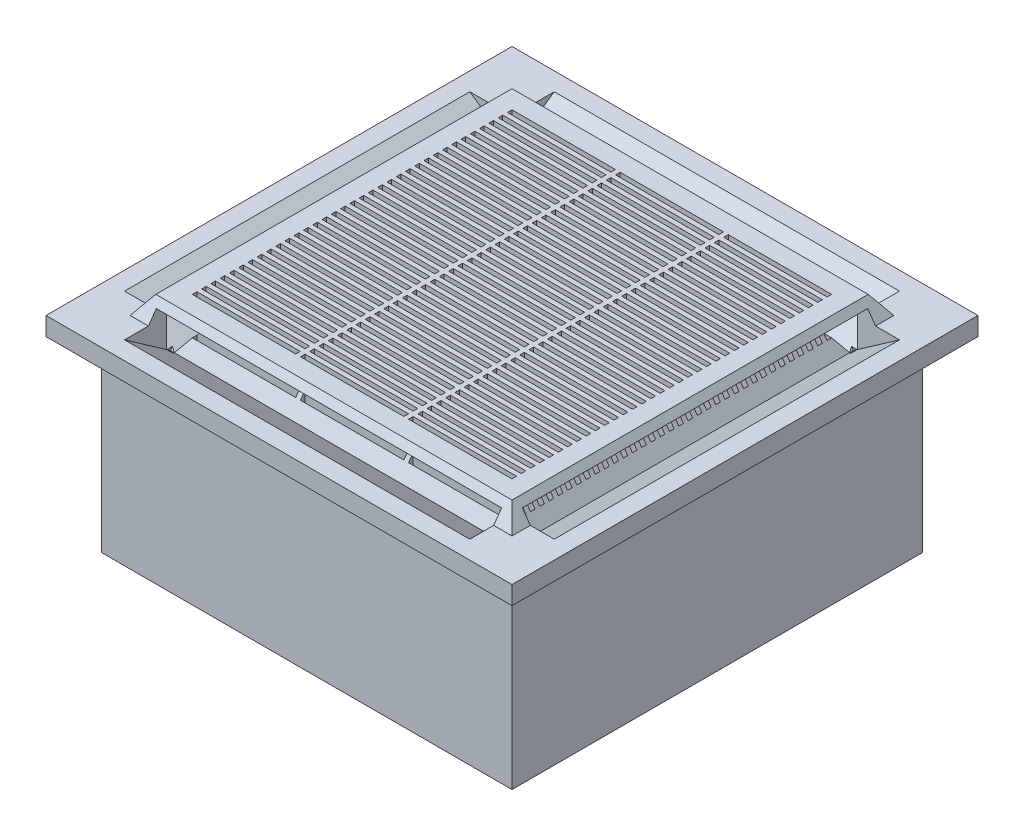
from build123d import *

# Parameters (mm, degrees)
SKETCH1_W           = 569.976
SKETCH1_H           = 569.976
BOSS_EXTRUDE1_DEPTH = 260.096
SKETCH3_W           = 646.938
SKETCH3_H           = 646.938
BOSS_EXTRUDE2_DEPTH = 50.8
SKETCH4_W           = 143.51
SKETCH4_H           = 6.35
CUT_EXTRUDE2_DEPTH  = 101.6
SKETCH5_W           = 799.338
SKETCH5_H           = 799.338
SKETCH5_W_2         = 494.538
SKETCH5_H_2         = 494.538
CUT_EXTRUDE3_DEPTH  = 25.4
CUT_EXTRUDE3_TAPER  = 35
SKETCH6_W           = 479.308542942
SKETCH6_H           = 38.1
CUT_EXTRUDE4_DEPTH  = 50.8
SKETCH7_W           = 479.308542942
SKETCH7_H           = 38.1
CUT_EXTRUDE5_DEPTH  = 50.8
SKETCH8_W           = 479.308542942
SKETCH8_H           = 38.1
CUT_EXTRUDE6_DEPTH  = 50.8
SKETCH9_W           = 479.308542942
SKETCH9_H           = 38.1
CUT_EXTRUDE7_DEPTH  = 50.8
SKETCH10_W          = 544.576
SKETCH10_H          = 544.576
CUT_EXTRUDE8_DEPTH  = 221.996


with BuildPart() as part:
    # Sketch1 → Boss-Extrude1 (new body)
    with BuildSketch(Plane(origin=(0, 0, 0), x_dir=(1, 0, 0), z_dir=(0, 1, 0))):
        Rectangle(SKETCH1_W, SKETCH1_H)
    extrude(amount=BOSS_EXTRUDE1_DEPTH)

    # Sketch3 → Boss-Extrude2 (add)
    with BuildSketch(Plane(origin=(0, 260.096, 0), x_dir=(1, 0, 0), z_dir=(0, 1, 0))):
        with Locations((0.508, -0.508)):
            Rectangle(SKETCH3_W, SKETCH3_H)
    extrude(amount=BOSS_EXTRUDE2_DEPTH)

    # Sketch4 → Cut-Extrude2 (cut)
    with BuildSketch(Plane(origin=(0, 310.896, 0), x_dir=(1, 0, 0), z_dir=(0, 1, 0))):
        with Locations((-149.606, 218.186)):
            Rectangle(SKETCH4_W, SKETCH4_H)
        with Locations((0.508, 218.186)):
            Rectangle(SKETCH4_W, SKETCH4_H)
        with Locations((150.622, 218.186)):
            Rectangle(SKETCH4_W, SKETCH4_H)
        with Locations((0.508, 205.321647059)):
            Rectangle(SKETCH4_W, SKETCH4_H)
        with Locations((150.622, 205.321647059)):
            Rectangle(SKETCH4_W, SKETCH4_H)
        with Locations((0.508, 192.457294118)):
            Rectangle(SKETCH4_W, SKETCH4_H)
        with Locations((150.622, 192.457294118)):
            Rectangle(SKETCH4_W, SKETCH4_H)
        with Locations((0.508, 179.592941176)):
            Rectangle(SKETCH4_W, SKETCH4_H)
        with Locations((150.622, 179.592941176)):
            Rectangle(SKETCH4_W, SKETCH4_H)
        with Locations((0.508, 166.728588235)):
            Rectangle(SKETCH4_W, SKETCH4_H)
        with Locations((150.622, 166.728588235)):
            Rectangle(SKETCH4_W, SKETCH4_H)
        with Locations((0.508, 153.864235294)):
            Rectangle(SKETCH4_W, SKETCH4_H)
        with Locations((150.622, 153.864235294)):
            Rectangle(SKETCH4_W, SKETCH4_H)
        with Locations((0.508, 140.999882353)):
            Rectangle(SKETCH4_W, SKETCH4_H)
        with Locations((150.622, 140.999882353)):
            Rectangle(SKETCH4_W, SKETCH4_H)
        with Locations((0.508, 128.135529412)):
            Rectangle(SKETCH4_W, SKETCH4_H)
        with Locations((150.622, 128.135529412)):
            Rectangle(SKETCH4_W, SKETCH4_H)
        with Locations((0.508, 115.271176471)):
            Rectangle(SKETCH4_W, SKETCH4_H)
        with Locations((150.622, 115.271176471)):
            Rectangle(SKETCH4_W, SKETCH4_H)
        with Locations((0.508, 102.406823529)):
            Rectangle(SKETCH4_W, SKETCH4_H)
        with Locations((150.622, 102.406823529)):
            Rectangle(SKETCH4_W, SKETCH4_H)
        with Locations((0.508, 89.542470588)):
            Rectangle(SKETCH4_W, SKETCH4_H)
        with Locations((150.622, 89.542470588)):
            Rectangle(SKETCH4_W, SKETCH4_H)
        with Locations((0.508, 76.678117647)):
            Rectangle(SKETCH4_W, SKETCH4_H)
        with Locations((150.622, 76.678117647)):
            Rectangle(SKETCH4_W, SKETCH4_H)
        with Locations((0.508, 63.813764706)):
            Rectangle(SKETCH4_W, SKETCH4_H)
        with Locations((150.622, 63.813764706)):
            Rectangle(SKETCH4_W, SKETCH4_H)
        with Locations((0.508, 50.949411765)):
            Rectangle(SKETCH4_W, SKETCH4_H)
        with Locations((150.622, 50.949411765)):
            Rectangle(SKETCH4_W, SKETCH4_H)
        with Locations((0.508, 38.085058824)):
            Rectangle(SKETCH4_W, SKETCH4_H)
        with Locations((150.622, 38.085058824)):
            Rectangle(SKETCH4_W, SKETCH4_H)
        with Locations((0.508, 25.220705882)):
            Rectangle(SKETCH4_W, SKETCH4_H)
        with Locations((150.622, 25.220705882)):
            Rectangle(SKETCH4_W, SKETCH4_H)
        with Locations((0.508, 12.356352941)):
            Rectangle(SKETCH4_W, SKETCH4_H)
        with Locations((150.622, 12.356352941)):
            Rectangle(SKETCH4_W, SKETCH4_H)
        with Locations((0.508, -0.508)):
            Rectangle(SKETCH4_W, SKETCH4_H)
        with Locations((150.622, -0.508)):
            Rectangle(SKETCH4_W, SKETCH4_H)
        with Locations((0.508, -13.372352941)):
            Rectangle(SKETCH4_W, SKETCH4_H)
        with Locations((150.622, -13.372352941)):
            Rectangle(SKETCH4_W, SKETCH4_H)
        with Locations((0.508, -26.236705882)):
            Rectangle(SKETCH4_W, SKETCH4_H)
        with Locations((150.622, -26.236705882)):
            Rectangle(SKETCH4_W, SKETCH4_H)
        with Locations((0.508, -39.101058824)):
            Rectangle(SKETCH4_W, SKETCH4_H)
        with Locations((150.622, -39.101058824)):
            Rectangle(SKETCH4_W, SKETCH4_H)
        with Locations((0.508, -51.965411765)):
            Rectangle(SKETCH4_W, SKETCH4_H)
        with Locations((150.622, -51.965411765)):
            Rectangle(SKETCH4_W, SKETCH4_H)
        with Locations((0.508, -64.829764706)):
            Rectangle(SKETCH4_W, SKETCH4_H)
        with Locations((150.622, -64.829764706)):
            Rectangle(SKETCH4_W, SKETCH4_H)
        with Locations((0.508, -77.694117647)):
            Rectangle(SKETCH4_W, SKETCH4_H)
        with Locations((150.622, -77.694117647)):
            Rectangle(SKETCH4_W, SKETCH4_H)
        with Locations((0.508, -90.558470588)):
            Rectangle(SKETCH4_W, SKETCH4_H)
        with Locations((150.622, -90.558470588)):
            Rectangle(SKETCH4_W, SKETCH4_H)
        with Locations((0.508, -103.422823529)):
            Rectangle(SKETCH4_W, SKETCH4_H)
        with Locations((150.622, -103.422823529)):
            Rectangle(SKETCH4_W, SKETCH4_H)
        with Locations((0.508, -116.287176471)):
            Rectangle(SKETCH4_W, SKETCH4_H)
        with Locations((150.622, -116.287176471)):
            Rectangle(SKETCH4_W, SKETCH4_H)
        with Locations((0.508, -129.151529412)):
            Rectangle(SKETCH4_W, SKETCH4_H)
        with Locations((150.622, -129.151529412)):
            Rectangle(SKETCH4_W, SKETCH4_H)
        with Locations((0.508, -142.015882353)):
            Rectangle(SKETCH4_W, SKETCH4_H)
        with Locations((150.622, -142.015882353)):
            Rectangle(SKETCH4_W, SKETCH4_H)
        with Locations((0.508, -154.880235294)):
            Rectangle(SKETCH4_W, SKETCH4_H)
        with Locations((150.622, -154.880235294)):
            Rectangle(SKETCH4_W, SKETCH4_H)
        with Locations((0.508, -167.744588235)):
            Rectangle(SKETCH4_W, SKETCH4_H)
        with Locations((150.622, -167.744588235)):
            Rectangle(SKETCH4_W, SKETCH4_H)
        with Locations((0.508, -180.608941176)):
            Rectangle(SKETCH4_W, SKETCH4_H)
        with Locations((150.622, -180.608941176)):
            Rectangle(SKETCH4_W, SKETCH4_H)
        with Locations((0.508, -193.473294118)):
            Rectangle(SKETCH4_W, SKETCH4_H)
        with Locations((150.622, -193.473294118)):
            Rectangle(SKETCH4_W, SKETCH4_H)
        with Locations((0.508, -206.337647059)):
            Rectangle(SKETCH4_W, SKETCH4_H)
        with Locations((150.622, -206.337647059)):
            Rectangle(SKETCH4_W, SKETCH4_H)
        with Locations((0.508, -219.202)):
            Rectangle(SKETCH4_W, SKETCH4_H)
        with Locations((150.622, -219.202)):
            Rectangle(SKETCH4_W, SKETCH4_H)
        with Locations((-149.606, 205.321647059)):
            Rectangle(SKETCH4_W, SKETCH4_H)
        with Locations((-149.606, 192.457294118)):
            Rectangle(SKETCH4_W, SKETCH4_H)
        with Locations((-149.606, 179.592941176)):
            Rectangle(SKETCH4_W, SKETCH4_H)
        with Locations((-149.606, 166.728588235)):
            Rectangle(SKETCH4_W, SKETCH4_H)
        with Locations((-149.606, 153.864235294)):
            Rectangle(SKETCH4_W, SKETCH4_H)
        with Locations((-149.606, 140.999882353)):
            Rectangle(SKETCH4_W, SKETCH4_H)
        with Locations((-149.606, 128.135529412)):
            Rectangle(SKETCH4_W, SKETCH4_H)
        with Locations((-149.606, 115.271176471)):
            Rectangle(SKETCH4_W, SKETCH4_H)
        with Locations((-149.606, 102.406823529)):
            Rectangle(SKETCH4_W, SKETCH4_H)
        with Locations((-149.606, 89.542470588)):
            Rectangle(SKETCH4_W, SKETCH4_H)
        with Locations((-149.606, 76.678117647)):
            Rectangle(SKETCH4_W, SKETCH4_H)
        with Locations((-149.606, 63.813764706)):
            Rectangle(SKETCH4_W, SKETCH4_H)
        with Locations((-149.606, 50.949411765)):
            Rectangle(SKETCH4_W, SKETCH4_H)
        with Locations((-149.606, 38.085058824)):
            Rectangle(SKETCH4_W, SKETCH4_H)
        with Locations((-149.606, 25.220705882)):
            Rectangle(SKETCH4_W, SKETCH4_H)
        with Locations((-149.606, 12.356352941)):
            Rectangle(SKETCH4_W, SKETCH4_H)
        with Locations((-149.606, -0.508)):
            Rectangle(SKETCH4_W, SKETCH4_H)
        with Locations((-149.606, -13.372352941)):
            Rectangle(SKETCH4_W, SKETCH4_H)
        with Locations((-149.606, -26.236705882)):
            Rectangle(SKETCH4_W, SKETCH4_H)
        with Locations((-149.606, -39.101058824)):
            Rectangle(SKETCH4_W, SKETCH4_H)
        with Locations((-149.606, -51.965411765)):
            Rectangle(SKETCH4_W, SKETCH4_H)
        with Locations((-149.606, -64.829764706)):
            Rectangle(SKETCH4_W, SKETCH4_H)
        with Locations((-149.606, -77.694117647)):
            Rectangle(SKETCH4_W, SKETCH4_H)
        with Locations((-149.606, -90.558470588)):
            Rectangle(SKETCH4_W, SKETCH4_H)
        with Locations((-149.606, -103.422823529)):
            Rectangle(SKETCH4_W, SKETCH4_H)
        with Locations((-149.606, -116.287176471)):
            Rectangle(SKETCH4_W, SKETCH4_H)
        with Locations((-149.606, -129.151529412)):
            Rectangle(SKETCH4_W, SKETCH4_H)
        with Locations((-149.606, -142.015882353)):
            Rectangle(SKETCH4_W, SKETCH4_H)
        with Locations((-149.606, -154.880235294)):
            Rectangle(SKETCH4_W, SKETCH4_H)
        with Locations((-149.606, -167.744588235)):
            Rectangle(SKETCH4_W, SKETCH4_H)
        with Locations((-149.606, -180.608941176)):
            Rectangle(SKETCH4_W, SKETCH4_H)
        with Locations((-149.606, -193.473294118)):
            Rectangle(SKETCH4_W, SKETCH4_H)
        with Locations((-149.606, -206.337647059)):
            Rectangle(SKETCH4_W, SKETCH4_H)
        with Locations((-149.606, -219.202)):
            Rectangle(SKETCH4_W, SKETCH4_H)
    extrude(amount=-CUT_EXTRUDE2_DEPTH, mode=Mode.SUBTRACT)

    # Sketch5 → Cut-Extrude3 (cut)
    with BuildSketch(Plane(origin=(0, 310.896, 0), x_dir=(1, 0, 0), z_dir=(0, 1, 0))):
        with Locations((0.508, -0.508)):
            Rectangle(SKETCH5_W, SKETCH5_H)
        with Locations((0.508, -0.508)):
            Rectangle(SKETCH5_W_2, SKETCH5_H_2, mode=Mode.SUBTRACT)
    extrude(amount=-CUT_EXTRUDE3_DEPTH, taper=CUT_EXTRUDE3_TAPER, mode=Mode.SUBTRACT)

    # Sketch6 → Cut-Extrude4 (cut, symmetric)
    with BuildSketch(Plane(origin=(312.334201042, 218.698762011, 0), x_dir=(0, 0, -1), z_dir=(0.819152044, 0.573576436, 0))):
        with Locations((-0.508, 81.544370737)):
            Rectangle(SKETCH6_W, SKETCH6_H)
    extrude(amount=CUT_EXTRUDE4_DEPTH, both=True, mode=Mode.SUBTRACT)

    # Sketch7 → Cut-Extrude5 (cut, symmetric)
    with BuildSketch(Plane(origin=(0, 218.221398159, -311.65245481), x_dir=(-1, 0, 0), z_dir=(0, 0.573576436, -0.819152044))):
        with Locations((-0.508, 82.127124396)):
            Rectangle(SKETCH7_W, SKETCH7_H)
    extrude(amount=CUT_EXTRUDE5_DEPTH, both=True, mode=Mode.SUBTRACT)

    # Sketch8 → Cut-Extrude6 (cut, symmetric)
    with BuildSketch(Plane(origin=(-311.65245481, 218.221398159, 0), x_dir=(0, 0, 1), z_dir=(-0.819152044, 0.573576436, 0))):
        with Locations((0.508, 82.127124396)):
            Rectangle(SKETCH8_W, SKETCH8_H)
    extrude(amount=CUT_EXTRUDE6_DEPTH, both=True, mode=Mode.SUBTRACT)

    # Sketch9 → Cut-Extrude7 (cut, symmetric)
    with BuildSketch(Plane(origin=(0, 218.698762011, 312.334201042), x_dir=(1, 0, 0), z_dir=(0, 0.573576436, 0.819152044))):
        with Locations((0.508, 81.544370737)):
            Rectangle(SKETCH9_W, SKETCH9_H)
    extrude(amount=CUT_EXTRUDE7_DEPTH, both=True, mode=Mode.SUBTRACT)

    # Sketch10 → Cut-Extrude8 (cut)
    with BuildSketch(Plane(origin=(0, 12.7, 0), x_dir=(-1, 0, 0), z_dir=(0, -1, 0))):
        Rectangle(SKETCH10_W, SKETCH10_H)
    extrude(amount=-CUT_EXTRUDE8_DEPTH, mode=Mode.SUBTRACT)


solid = part.part
